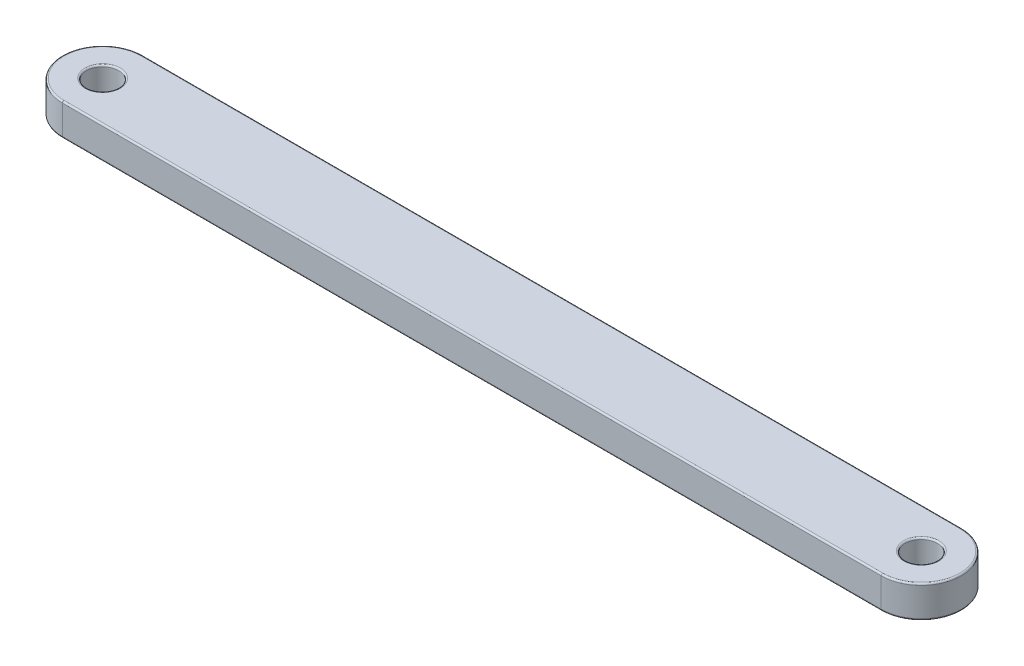
from build123d import *

# Parameters (mm, degrees)
SKETCH1_R           = 10
BOSS_EXTRUDE1_DEPTH = 20
FILLET1_R           = 1
SCALE1_SCALE        = 0.125


with BuildPart() as part:
    # Sketch1 → Boss-Extrude1 (new body)
    with BuildSketch(Plane(origin=(0, 0, 0), x_dir=(1, 0, 0), z_dir=(0, 1, 0))):
        with BuildLine():
            Line((-255, 25), (255, 25))
            ThreePointArc((255, 25), (280, 0), (255, -25))
            Line((255, -25), (-255, -25))
            ThreePointArc((-255, -25), (-280, 0), (-255, 25))
        make_face()
        with Locations((-255, 0)):
            Circle(SKETCH1_R, mode=Mode.SUBTRACT)
        with Locations((255, 0)):
            Circle(SKETCH1_R, mode=Mode.SUBTRACT)
    extrude(amount=BOSS_EXTRUDE1_DEPTH)

    # Fillet1
    fillet1_edges = [part.edges().sort_by_distance(p)[0] for p in [
        (-265, 0, 0),
        (-265, 20, 0),
        (280, 20, 0),
        (245, 0, 0),
        (245, 20, 0),
        (0, 20, -25),
        (-280, 20, 0),
        (0, 0, -25),
        (280, 0, 0),
        (0, 0, 25),
        (-280, 0, 0),
        (0, 20, 25),
    ]]
    fillet(fillet1_edges, radius=FILLET1_R)


with BuildPart() as part_1:
    # Scale1: scaled about (0, 10, 0)
    add(part.part.scale(SCALE1_SCALE).moved(Location((0, 8.75, 0))))


solid = part_1.part
